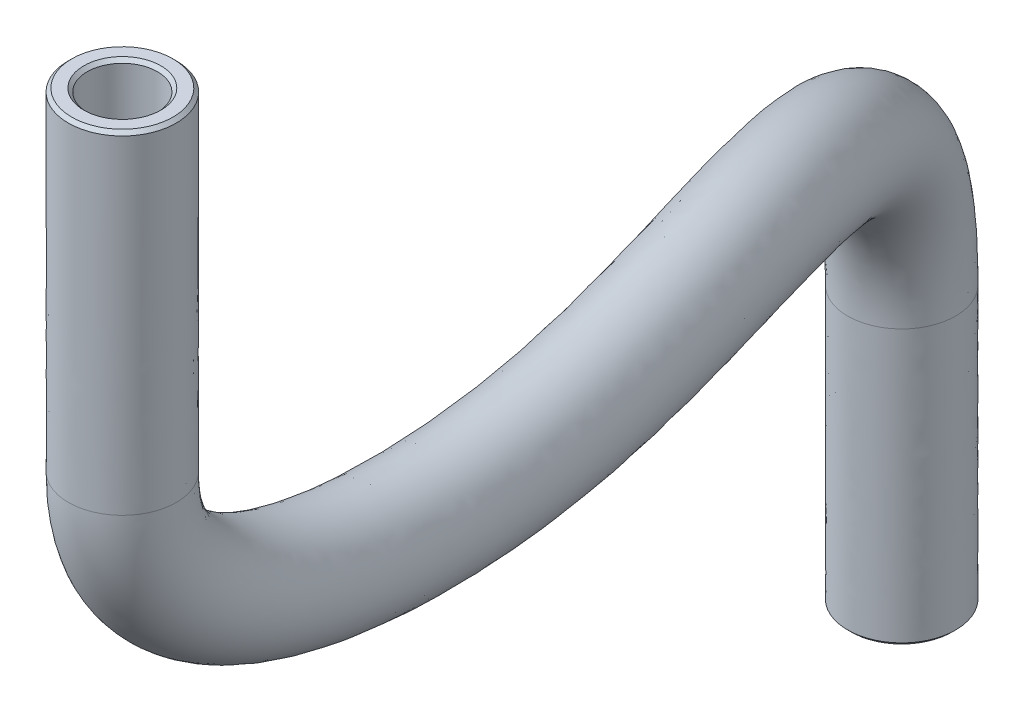
from build123d import *

# Parameters (mm, degrees)
SKETCH1_R     = 2
SKETCH1_R_2   = 1.3
CHAMFER1_SIZE = 0.127


with BuildPart() as part:
    # Sweep1: sweep along a curve in space
    with BuildLine() as sweep1_path:
        Line((104.325, -62.025, 13.85), (104.325, -74.325, 13.85))
        add(Edge.make_bspline(
            [(104.325, -74.325, 13.85), (104.325, -80.910814456, 13.85), (104.776488709, -83.509139856, -5.8375), (93.825, -83.330072547, -25.525), (93.825, -93.282256564, -25.525)],
            knots=[0, 0, 0, 0, 0.439595441, 1, 1, 1, 1], degree=3))
        Line((93.825, -93.282256564, -25.525), (93.825, -103.482256564, -25.525))
    # Sketch1 → Sweep1 (sweep)
    with BuildSketch(Plane(origin=(0, -95.382256564, 0), x_dir=(1, 0, 0), z_dir=(0, 1, 0))):
        with Locations((93.825, 25.525)):
            Circle(SKETCH1_R)
        with Locations((93.825, 25.525)):
            Circle(SKETCH1_R_2, mode=Mode.SUBTRACT)
    sweep(path=sweep1_path.line)

    # Chamfer1
    chamfer1_edges = [part.edges().sort_by_distance(p)[0] for p in [
        (103.108926594, -62.025, 13.390472555),
        (92.525, -103.482256564, -25.525),
        (102.454117838, -62.025, 13.143034701),
        (91.825, -103.482256564, -25.525),
    ]]
    chamfer(chamfer1_edges, length=CHAMFER1_SIZE)


solid = part.part
